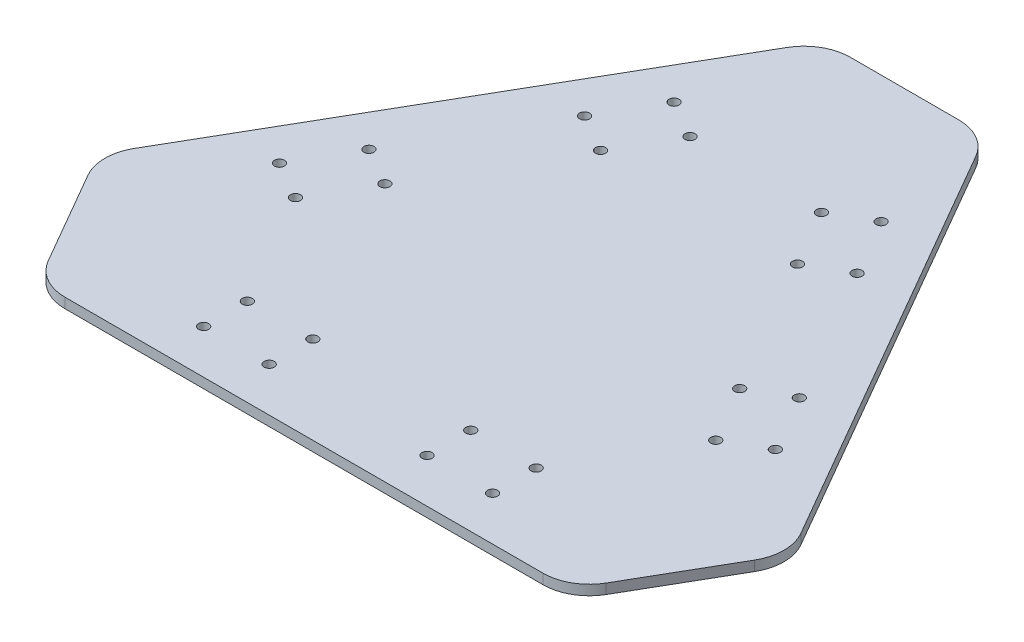
from build123d import *

# Parameters (mm, degrees)
BOSS_EXTRUDE1_DEPTH         = 2.75
FILLET1_R                   = 12.7
SKETCH5_R                   = 1.3890625
CUT_EXTRUDE4_DEPTH          = 135.761205832
CIRPATTERN2_COUNT           = 3
CIRPATTERN2_COPY_1_SKETCH_R = 1.3890625
CIRPATTERN2_COPY_1_DEPTH    = 135.761205832
CIRPATTERN2_COPY_2_SKETCH_R = 1.3890625
CIRPATTERN2_COPY_2_DEPTH    = 135.761205832


with BuildPart() as part:
    # Sketch1 → Boss-Extrude1 (new body)
    with BuildSketch(Plane(origin=(0, 0, 0), x_dir=(1, 0, 0), z_dir=(0, 1, 0))):
        Polygon((-22.265317244, 97.17689372), (22.265317244, 97.17689372), (95.290317244, -29.306116503), (73.025, -67.870777217), (-73.025, -67.870777217), (-95.290317244, -29.306116503), align=None)
    extrude(amount=BOSS_EXTRUDE1_DEPTH)

    # Fillet1
    fillet1_edges = [part.edges().sort_by_distance(p)[0] for p in [
        (-22.265317244, 1.375, -97.17689372),
        (22.265317244, 1.375, -97.17689372),
        (95.290317244, 1.375, 29.306116503),
        (73.025, 1.375, 67.870777217),
        (-95.290317244, 1.375, 29.306116503),
        (-73.025, 1.375, 67.870777217),
    ]]
    fillet(fillet1_edges, radius=FILLET1_R)

    # Sketch5 → Cut-Extrude4 (cut, through all)
    with BuildSketch(Plane(origin=(0, 2.75, 0), x_dir=(1, 0, 0), z_dir=(0, 1, 0))):
        with Locations((21.7, -43.775677217)):
            Circle(SKETCH5_R)
        with Locations((21.7, -55.775677217)):
            Circle(SKETCH5_R)
        with Locations((39.7, -43.775677217)):
            Circle(SKETCH5_R)
        with Locations((39.7, -55.775677217)):
            Circle(SKETCH5_R)
    cut_extrude4 = extrude(amount=-CUT_EXTRUDE4_DEPTH, mode=Mode.SUBTRACT)

    # Mirror1: Cut-Extrude4 across plane
    add(cut_extrude4.mirror(Plane(origin=(0, 0, 0), x_dir=(0, 0, 1), z_dir=(1, 0, 0))), mode=Mode.SUBTRACT)

    # CirPattern2: Cut-Extrude4 ×3 about axis
    cirpattern2_axis = Axis((0, 0, 0), (0, 1, 0))
    for i in range(1, CIRPATTERN2_COUNT):
        add(cut_extrude4.rotate(cirpattern2_axis, i * 360 / CIRPATTERN2_COUNT), mode=Mode.SUBTRACT)

    # CirPattern2 copy 1 sketch → CirPattern2 copy 1 (cut, through all)
    with BuildSketch(Plane(origin=(0, 2.75, 0), x_dir=(0.4999999999999998, 0, 0.8660254037844387), z_dir=(0, 1, 0))):
        with Locations((21.7, 43.775677217)):
            Circle(CIRPATTERN2_COPY_1_SKETCH_R)
        with Locations((21.7, 55.775677217)):
            Circle(CIRPATTERN2_COPY_1_SKETCH_R)
        with Locations((39.7, 43.775677217)):
            Circle(CIRPATTERN2_COPY_1_SKETCH_R)
        with Locations((39.7, 55.775677217)):
            Circle(CIRPATTERN2_COPY_1_SKETCH_R)
    extrude(amount=-CIRPATTERN2_COPY_1_DEPTH, mode=Mode.SUBTRACT)

    # CirPattern2 copy 2 sketch → CirPattern2 copy 2 (cut, through all)
    with BuildSketch(Plane(origin=(0, 2.75, 0), x_dir=(0.5000000000000004, 0, -0.8660254037844384), z_dir=(0, 1, 0))):
        with Locations((21.7, 43.775677217)):
            Circle(CIRPATTERN2_COPY_2_SKETCH_R)
        with Locations((21.7, 55.775677217)):
            Circle(CIRPATTERN2_COPY_2_SKETCH_R)
        with Locations((39.7, 43.775677217)):
            Circle(CIRPATTERN2_COPY_2_SKETCH_R)
        with Locations((39.7, 55.775677217)):
            Circle(CIRPATTERN2_COPY_2_SKETCH_R)
    extrude(amount=-CIRPATTERN2_COPY_2_DEPTH, mode=Mode.SUBTRACT)


solid = part.part
